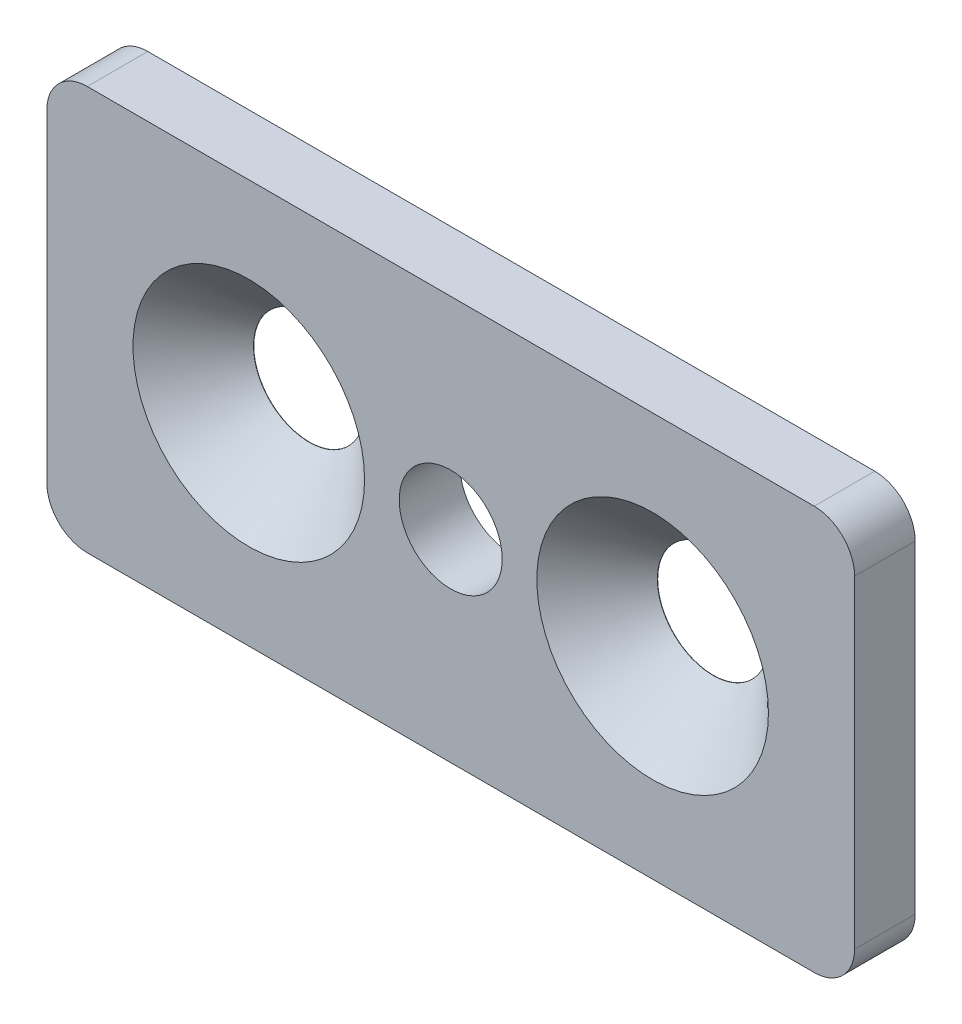
from build123d import *

# Parameters (mm, degrees)
CROQUIS1_R                                           = 2.55
SALIENTE_EXTRUIR1_DEPTH                              = 3
AVELLANADO_PARA_TORNILLO_CON_CABEZA_AVEL_D           = 5.5
AVELLANADO_PARA_TORNILLO_CON_CABEZA_AVEL_DEPTH       = 5
AVELLANADO_PARA_TORNILLO_CON_CABEZA_AVEL_CSINK_D     = 11.47
AVELLANADO_PARA_TORNILLO_CON_CABEZA_AVEL_CSINK_ANGLE = 90
AVELLANADO_PARA_TORNILLO_CON_CABEZA_AVEL_TIP         = 1.652366702


with BuildPart() as part:
    # Croquis1 → Saliente-Extruir1 (new body)
    with BuildSketch(Plane.XY):
        with BuildLine():
            Line((2, 0), (38, 0))
            ThreePointArc((38, 0), (39.414213562, 0.585786438), (40, 2))
            Line((40, 2), (40, 18))
            ThreePointArc((40, 18), (39.414213562, 19.414213562), (38, 20))
            Line((38, 20), (2, 20))
            ThreePointArc((2, 20), (0.585786438, 19.414213562), (0, 18))
            Line((0, 18), (0, 2))
            ThreePointArc((0, 2), (0.585786438, 0.585786438), (2, 0))
        make_face()
        with Locations((10, 10)):
            Circle(CROQUIS1_R, mode=Mode.SUBTRACT)
        with Locations((20, 10)):
            Circle(CROQUIS1_R, mode=Mode.SUBTRACT)
        with Locations((30, 10)):
            Circle(CROQUIS1_R, mode=Mode.SUBTRACT)
    extrude(amount=SALIENTE_EXTRUIR1_DEPTH)

    # Avellanado para tornillo con cabeza avellanada de clavija hexagonal de M51
    with Locations(Plane.XY.offset(3)):
        with Locations((10, 10), (30, 10)):
            CounterSinkHole(AVELLANADO_PARA_TORNILLO_CON_CABEZA_AVEL_D / 2, AVELLANADO_PARA_TORNILLO_CON_CABEZA_AVEL_CSINK_D / 2, depth=AVELLANADO_PARA_TORNILLO_CON_CABEZA_AVEL_DEPTH, counter_sink_angle=AVELLANADO_PARA_TORNILLO_CON_CABEZA_AVEL_CSINK_ANGLE)
            with Locations((0, 0, -(AVELLANADO_PARA_TORNILLO_CON_CABEZA_AVEL_DEPTH + AVELLANADO_PARA_TORNILLO_CON_CABEZA_AVEL_TIP / 2))):  # 118° drill point
                Cone(0, AVELLANADO_PARA_TORNILLO_CON_CABEZA_AVEL_D / 2, AVELLANADO_PARA_TORNILLO_CON_CABEZA_AVEL_TIP, mode=Mode.SUBTRACT)


solid = part.part
